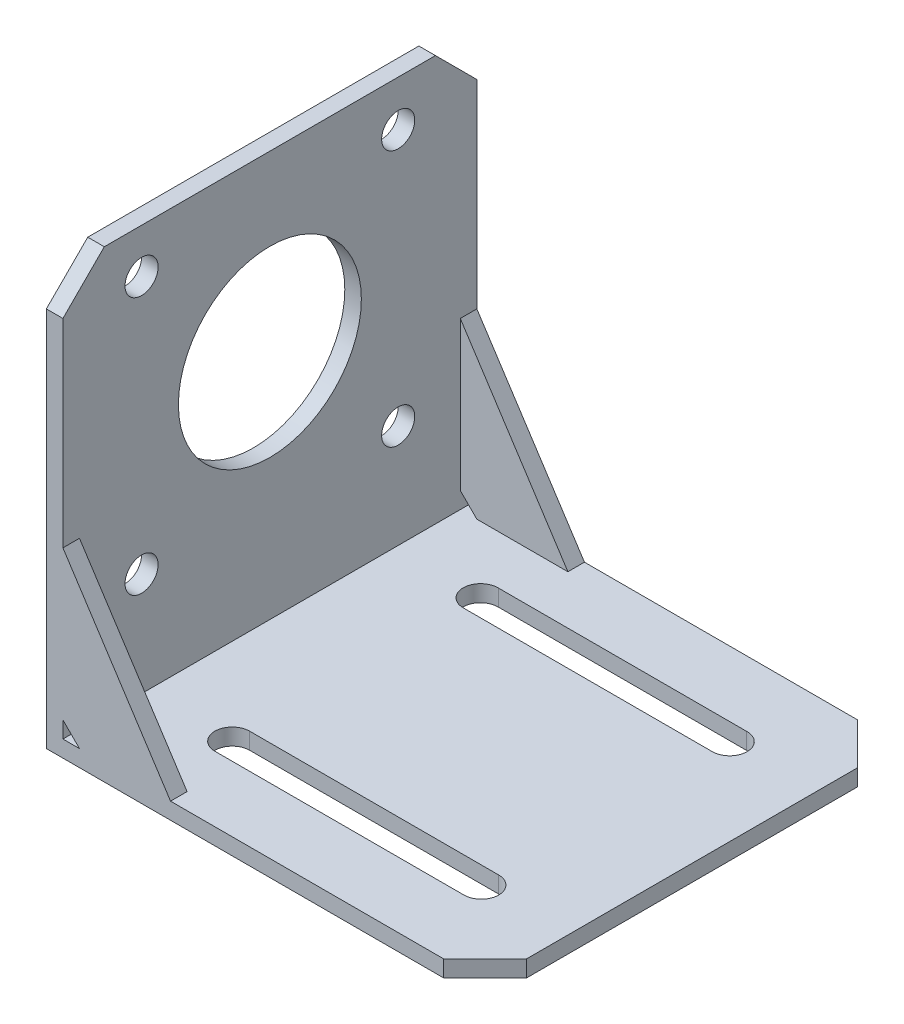
from build123d import *

# Parameters (mm, degrees)
BOSS_EXTRUDE1_DEPTH = 50
SKETCH2_R           = 11.05
SKETCH2_R_2         = 2
CUT_EXTRUDE1_DEPTH  = 3
CUT_EXTRUDE2_DEPTH  = 50
BOSS_EXTRUDE2_DEPTH = 2
BOSS_EXTRUDE3_DEPTH = 2
CHAMFER1_SIZE       = 5


with BuildPart() as part:
    # Sketch1 → Boss-Extrude1 (new body)
    with BuildSketch(Plane.XY):
        Polygon((0, 0), (0, 51), (2, 51), (2, 2), (53, 2), (53, 0), align=None)
    extrude(amount=BOSS_EXTRUDE1_DEPTH)

    # Sketch2 → Cut-Extrude1 (cut, through all)
    with BuildSketch(Plane(origin=(2, 0, 0), x_dir=(0, 0, -1), z_dir=(1, 0, 0))):
        with Locations((-25, 30)):
            Circle(SKETCH2_R)
        with Locations((-40.5, 45.640445987)):
            Circle(SKETCH2_R_2)
        with Locations((-9.5, 45.5)):
            Circle(SKETCH2_R_2)
        with Locations((-40.5, 14.5)):
            Circle(SKETCH2_R_2)
        with Locations((-9.5, 14.5)):
            Circle(SKETCH2_R_2)
    extrude(amount=-CUT_EXTRUDE1_DEPTH, mode=Mode.SUBTRACT)

    # Sketch3 → Cut-Extrude2 (cut)
    with BuildSketch(Plane(origin=(0, 2, 0), x_dir=(1, 0, 0), z_dir=(0, 1, 0))):
        with BuildLine():
            Line((12.455251015, -12.1), (42.544748985, -12.1))
            ThreePointArc((42.544748985, -12.1), (44.644629774, -9.977624237), (42.5, -7.900476833))
            Line((42.5, -7.900476833), (12.5, -7.900476833))
            ThreePointArc((12.5, -7.900476833), (10.355370226, -9.977624237), (12.455251015, -12.1))
        make_face()
        with BuildLine():
            Line((12.5, -42.099523167), (42.5, -42.099523167))
            ThreePointArc((42.5, -42.099523167), (44.644629774, -40.022375763), (42.544748985, -37.9))
            Line((42.544748985, -37.9), (12.455251015, -37.9))
            ThreePointArc((12.455251015, -37.9), (10.355370226, -40.022375763), (12.5, -42.099523167))
        make_face()
    extrude(amount=-CUT_EXTRUDE2_DEPTH, mode=Mode.SUBTRACT)

    # Sketch5 → Boss-Extrude2 (add)
    with BuildSketch(Plane.XY.offset(50)):
        Polygon((2, 22), (2, 4), (4, 2), (15, 2), align=None)
    extrude(amount=-BOSS_EXTRUDE2_DEPTH)

    # Sketch6 → Boss-Extrude3 (add)
    with BuildSketch(Plane(origin=(0, 0, 0), x_dir=(-1, 0, 0), z_dir=(0, 0, -1))):
        Polygon((-4, 2), (-2, 4), (-2, 22), (-15, 2), align=None)
    extrude(amount=-BOSS_EXTRUDE3_DEPTH)

    # Chamfer1
    chamfer1_edges = [part.edges().sort_by_distance(p)[0] for p in [
        (1, 51, 50),
        (1, 51, 0),
        (53, 1, 50),
        (53, 1, 0),
    ]]
    chamfer(chamfer1_edges, length=CHAMFER1_SIZE)


solid = part.part
